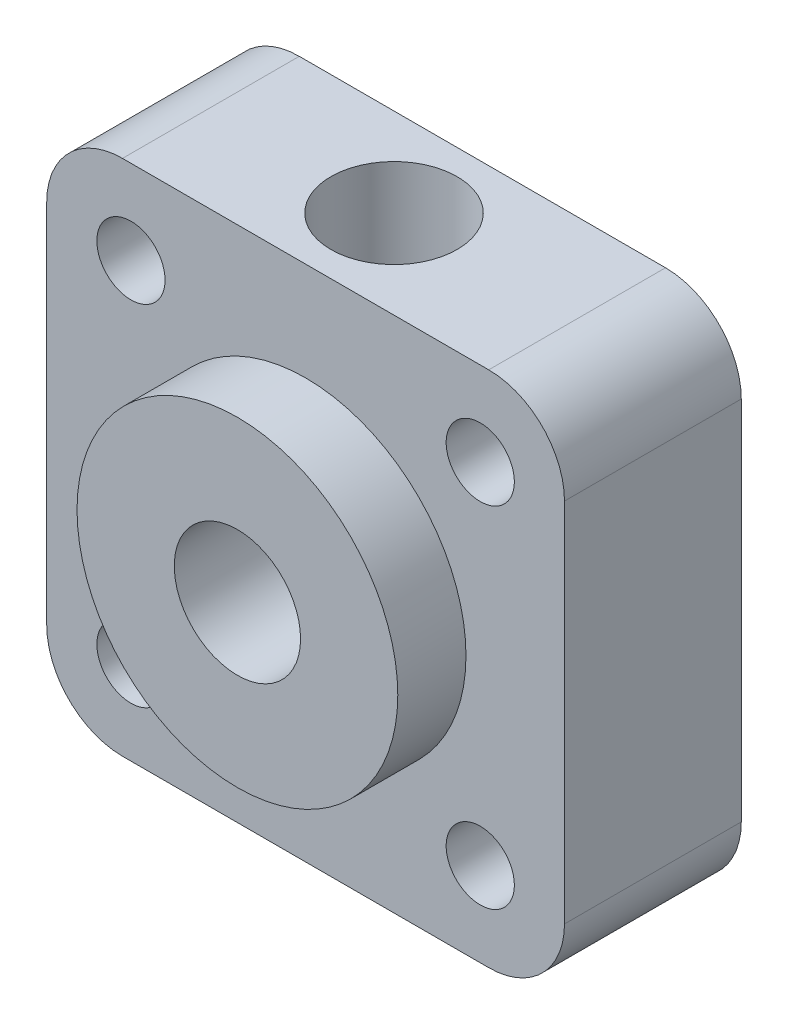
from build123d import *

# Parameters (mm, degrees)
CROQUIS1_W              = 20.5
CROQUIS1_H              = 20.5
SALIENTE_EXTRUIR1_DEPTH = 7
REDONDEO1_R             = 3
CROQUIS2_R              = 6.35
SALIENTE_EXTRUIR2_DEPTH = 2.7
CROQUIS3_R              = 2.5
CORTAR_EXTRUIR1_DEPTH   = 10.7
CROQUIS4_R              = 1.35
CORTAR_EXTRUIR2_DEPTH   = 8
CORTAR_EXTRUIR3_REACH   = 22.5
CROQUIS5_R              = 2.5


with BuildPart() as part:
    # Croquis1 → Saliente-Extruir1 (new body)
    with BuildSketch(Plane.XY):
        Rectangle(CROQUIS1_W, CROQUIS1_H)
    extrude(amount=SALIENTE_EXTRUIR1_DEPTH)

    # Redondeo1
    redondeo1_edges = [part.edges().sort_by_distance(p)[0] for p in [
        (10.25, -10.25, 3.5),
        (-10.25, -10.25, 3.5),
        (-10.25, 10.25, 3.5),
        (10.25, 10.25, 3.5),
    ]]
    fillet(redondeo1_edges, radius=REDONDEO1_R)

    # Croquis2 → Saliente-Extruir2 (add)
    with BuildSketch(Plane.XY.offset(7)):
        Circle(CROQUIS2_R)
    extrude(amount=SALIENTE_EXTRUIR2_DEPTH)

    # Croquis3 → Cortar-Extruir1 (cut, through all)
    with BuildSketch(Plane.XY.offset(9.7)):
        Circle(CROQUIS3_R)
    extrude(amount=-CORTAR_EXTRUIR1_DEPTH, mode=Mode.SUBTRACT)

    # Croquis4 → Cortar-Extruir2 (cut, through all)
    with BuildSketch(Plane.XY.offset(7)):
        with Locations((-6.91550432, 6.91550432)):
            Circle(CROQUIS4_R)
        with Locations((6.91550432, 6.91550432)):
            Circle(CROQUIS4_R)
        with Locations((6.91550432, -6.91550432)):
            Circle(CROQUIS4_R)
        with Locations((-6.91550432, -6.91550432)):
            Circle(CROQUIS4_R)
    extrude(amount=-CORTAR_EXTRUIR2_DEPTH, mode=Mode.SUBTRACT)

    # Croquis5 → Cortar-Extruir3 (cut, up to next)
    with BuildSketch(Plane(origin=(0, 10.25, 0), x_dir=(1, 0, 0), z_dir=(0, 1, 0)), mode=Mode.PRIVATE) as cortar_extruir3_sk1:
        with Locations((0, -3.5)):
            Circle(CROQUIS5_R)
    cortar_extruir3_tool1 = extrude(cortar_extruir3_sk1.sketch, amount=-CORTAR_EXTRUIR3_REACH, mode=Mode.PRIVATE) & part.part
    add(cortar_extruir3_tool1.solids().sort_by_distance((0, 10.25, 3.5))[0], mode=Mode.SUBTRACT)


solid = part.part
